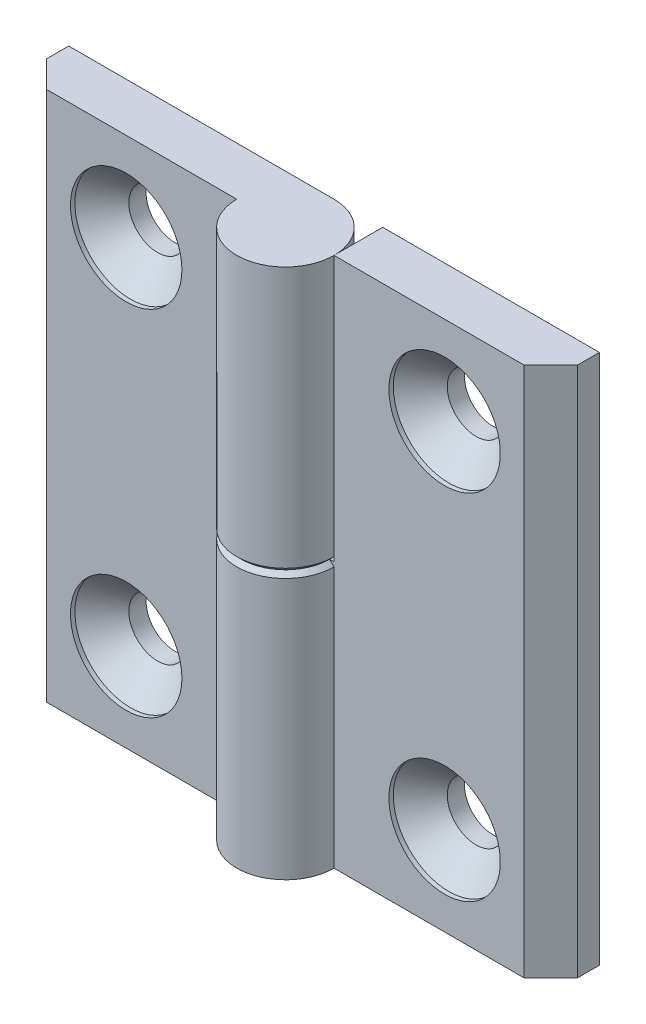
from build123d import *

# Parameters (mm, degrees)
EXTRUDE_1_DEPTH            = 30
SKETCH_3_W                 = 11
SKETCH_3_H                 = 30
CUT_EXTRUDE_1_DEPTH        = 6.5
CUT_EXTRUDE_1_DEPTH_BACK   = 6.5
HOLE_WIZARD_M61_AT_2_COUNT = 2
HOLE_WIZARD_M61_AT_2_PITCH = 40
CHAMFER_1_SIZE             = 0.5
PATTERN_CIRCULAR_1_COUNT   = 2


with BuildPart() as part:
    # Эскиз1 → Бобышка-Вытянуть1 (new body, symmetric)
    with BuildSketch(Plane(origin=(0, 0, 0), x_dir=(1, 0, 0), z_dir=(0, 1, 0))):
        with BuildLine():
            Line((0, 5.5), (-30, 5.5))
            Line((-30, 5.5), (-30, 3))
            Line((-30, 3), (-27, 0))
            Line((-27, 0), (-5.5, 0))
            ThreePointArc((-5.5, 0), (3.889087297, -3.889087297), (0, 5.5))
        make_face()
    extrude(amount=EXTRUDE_1_DEPTH, both=True)

    # Эскиз3 → Вырез-Вытянуть1 (cut, two sides)
    with BuildSketch(Plane.XY) as cut_extrude_1_sk:
        with Locations((0, -15)):
            Rectangle(SKETCH_3_W, SKETCH_3_H)
    extrude(amount=CUT_EXTRUDE_1_DEPTH, mode=Mode.SUBTRACT)
    extrude(cut_extrude_1_sk.sketch, amount=-CUT_EXTRUDE_1_DEPTH_BACK, mode=Mode.SUBTRACT)

    # Эскиз6 → Зенковка для винта с полупотайной головкой M61 (revolve, cut)
    with BuildSketch(Plane(origin=(-18, 20, 0), x_dir=(0, -1, 0), z_dir=(1, 0, 0))):
        Polygon((0, 0), (0, 5.5), (3.25, 5.5), (3.25, 3.55), (6.3, 0.5), (6.3, 0), align=None)
    hole_wizard_m61 = revolve(axis=Axis((-18, 20, 6.35), (0, 0, -1)), mode=Mode.SUBTRACT)

    # Зенковка для винта с полупотайной головкой M61 at 2: Зенковка для винта с полупотайной головкой M61 ×2
    with Locations(*[(0, -i * HOLE_WIZARD_M61_AT_2_PITCH, 0) for i in range(1, HOLE_WIZARD_M61_AT_2_COUNT)]):
        add(hole_wizard_m61, mode=Mode.SUBTRACT)

    # Фаска1
    chamfer_1_edges = [part.edges().sort_by_distance(p)[0] for p in [
        (3.889087297, 0, 3.889087297),
        (-2.75, 0, -5.5),
    ]]
    chamfer(chamfer_1_edges, length=CHAMFER_1_SIZE)


with BuildPart() as pattern_circular_1_1:
    # Круговой массив1: pattern copy
    add(part.part.rotate(Axis((0, 0, 0), (0, 0, 1)), 1 * 360 / PATTERN_CIRCULAR_1_COUNT))


solid = Compound([part.part, pattern_circular_1_1.part])
